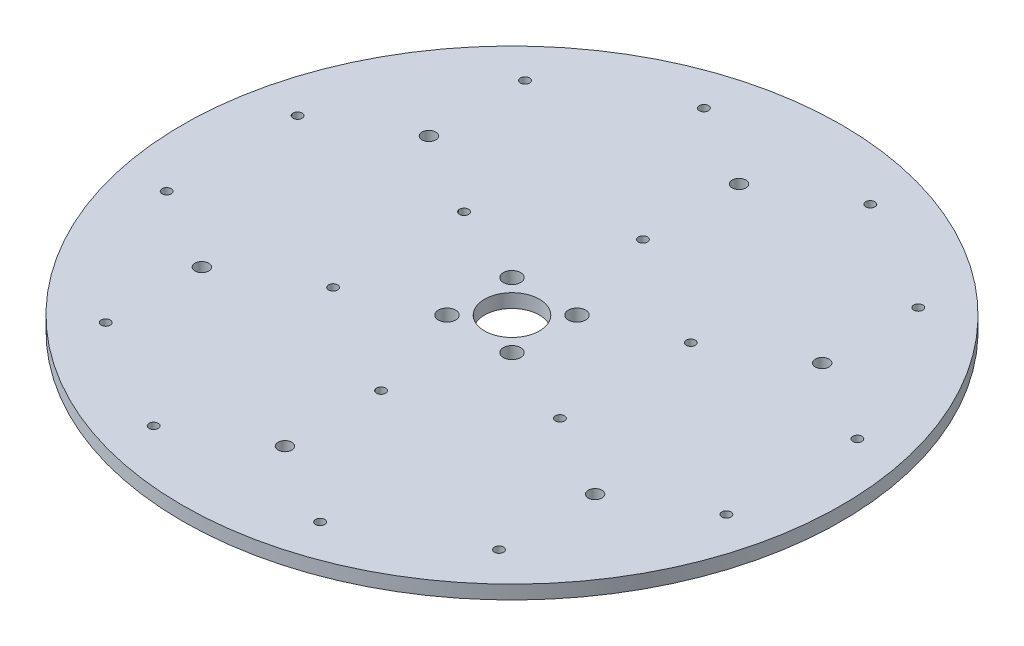
from build123d import *

# Parameters (mm, degrees)
SKETCH1_R                      = 152.4
BOSS_EXTRUDE1_DEPTH            = 6.35
M5X0_8_SET_SCREWS_D            = 4.2
SKETCH5_R                      = 3.175
CUT_EXTRUDE1_DEPTH             = 7.35
CIRPATTERN1_COUNT              = 6
SKETCH6_R                      = 12.7
CUT_EXTRUDE2_DEPTH             = 7.35
CBORE_FOR_M4_SHCS1_D           = 4.5
CBORE_FOR_M4_SHCS1_CBORE_D     = 8
CBORE_FOR_M4_SHCS1_CBORE_DEPTH = 6


with BuildPart() as part:
    # Sketch1 → Boss-Extrude1 (new body)
    with BuildSketch(Plane(origin=(0, 0, 0), x_dir=(1, 0, 0), z_dir=(0, 1, 0))):
        Circle(SKETCH1_R)
    extrude(amount=BOSS_EXTRUDE1_DEPTH)

    # M5x0.8 Set Screws (through all)
    with Locations(Plane(origin=(0, 6.35, 0), x_dir=(1, 0, 0), z_dir=(0, 1, 0))):
        with Locations((-38.494829198, 127.225), (38.494829198, 127.225), (0, 60.55)):
            m5x0_8_set_screws = Hole(M5X0_8_SET_SCREWS_D / 2)

    # Sketch5 → Cut-Extrude1 (cut, through all)
    with BuildSketch(Plane(origin=(0, 6.35, 0), x_dir=(1, 0, 0), z_dir=(0, 1, 0))):
        with Locations((0, 105)):
            Circle(SKETCH5_R)
    cut_extrude1 = extrude(amount=-CUT_EXTRUDE1_DEPTH, mode=Mode.SUBTRACT)

    # CirPattern1: M5x0.8 Set Screws, Cut-Extrude1 ×6 about axis
    cirpattern1_axis = Axis((0, 0, 0), (0, 1, 0))
    for i in range(1, CIRPATTERN1_COUNT):
        add(m5x0_8_set_screws.rotate(cirpattern1_axis, i * 360 / CIRPATTERN1_COUNT), mode=Mode.SUBTRACT)
        add(cut_extrude1.rotate(cirpattern1_axis, i * 360 / CIRPATTERN1_COUNT), mode=Mode.SUBTRACT)

    # Sketch6 → Cut-Extrude2 (cut, through all)
    with BuildSketch(Plane(origin=(0, 6.35, 0), x_dir=(1, 0, 0), z_dir=(0, 1, 0))):
        Circle(SKETCH6_R)
    extrude(amount=-CUT_EXTRUDE2_DEPTH, mode=Mode.SUBTRACT)

    # CBORE for M4 SHCS1 (through all)
    with Locations(Plane(origin=(0, 6.35, 0), x_dir=(1, 0, 0), z_dir=(0, 1, 0))):
        with Locations((-15.0260191, 15.0260191), (15.0260191, 15.0260191), (15.0260191, -15.0260191), (-15.0260191, -15.0260191)):
            CounterBoreHole(CBORE_FOR_M4_SHCS1_D / 2, CBORE_FOR_M4_SHCS1_CBORE_D / 2, CBORE_FOR_M4_SHCS1_CBORE_DEPTH)


solid = part.part
